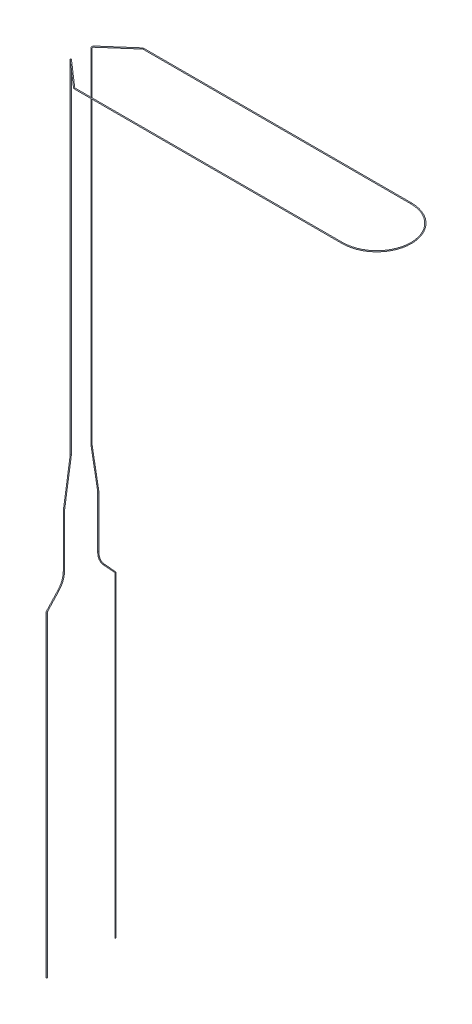
from build123d import *

# Parameters (mm, degrees)
BALAYAGE1_PROFILE_R = 0.25


with BuildPart() as part:
    # Balayage1: sweep along a curve in space
    with BuildLine() as balayage1_path:
        Line((0, -16.22597154, 20), (0, -200, 20))
        ThreePointArc((0, -15.547683614, 19.734796223), (0, -15.861826118, 19.931342102), (0, -16.22597154, 20))
        Line((0, -8.449455116, 13.182445327), (0, -15.547683614, 19.734796223))
        ThreePointArc((0, -0.31, 10), (0, -4.679745068, 10.823894773), (0, -8.449455116, 13.182445327))
        Line((0, 0, 10), (0, -0.31, 10))
        Line((0, 0, 10), (0, 29.23526781, 10))
        ThreePointArc((0, 29.23526781, 10), (0, 29.997773625, 9.970886865), (0, 30.755839653, 9.883716977))
        Line((0, 30.755839653, 9.883716977), (0, 55.244160347, 6.116283023))
        ThreePointArc((0, 56.76473219, 6), (0, 56.002226375, 6.029113135), (0, 55.244160347, 6.116283023))
        Line((0, 255, 6), (0, 56.76473219, 6))
        ThreePointArc((0.752576695, 256, 6.658504608), (0.220424611, 255.707106781, 6.192871534), (0, 255, 6))
        Line((0.752576695, 256, 6.658504608), (15.717230508, 256, 19.752576695))
        ThreePointArc((16.375735116, 256, 20), (16.024008443, 256, 19.936102744), (15.717230508, 256, 19.752576695))
        Line((16.375735116, 256, 20), (172, 256, 20))
        ThreePointArc((172, 256, 20), (192, 256, 0), (172, 256, -20))
        Line((16.375735116, 256, -20), (172, 256, -20))
        ThreePointArc((15.717230508, 256, -19.752576695), (16.024008443, 256, -19.936102744), (16.375735116, 256, -20))
        Line((0.752576695, 256, -6.658504608), (15.717230508, 256, -19.752576695))
        ThreePointArc((0, 255, -6), (0.220424611, 255.707106781, -6.192871534), (0.752576695, 256, -6.658504608))
        Line((0, 255, -6), (0, 56.76473219, -6))
        ThreePointArc((0, 55.244160347, -6.116283023), (0, 56.002226375, -6.029113135), (0, 56.76473219, -6))
        Line((0, 30.755839653, -9.883716977), (0, 55.244160347, -6.116283023))
        ThreePointArc((0, 30.755839653, -9.883716977), (0, 29.997773625, -9.970886865), (0, 29.23526781, -10))
        Line((0, 0, -10), (0, 29.23526781, -10))
        Line((0, 0, -10), (0, -0.31, -10))
        ThreePointArc((0, -8.449455116, -13.182445327), (0, -4.679745068, -10.823894773), (0, -0.31, -10))
        Line((0, -8.449455116, -13.182445327), (0, -15.547683614, -19.734796223))
        ThreePointArc((0, -16.22597154, -20), (0, -15.861826118, -19.931342102), (0, -15.547683614, -19.734796223))
        Line((0, -16.22597154, -20), (0, -200, -20))
    # Balayage1 profile (on start of the path) → Balayage1 (sweep)
    with BuildSketch(Plane(origin=(0, -200, -20), x_dir=(1, 0, 0), z_dir=(0, 1, 0))):
        Circle(BALAYAGE1_PROFILE_R)
    sweep(path=balayage1_path.line)


solid = part.part
